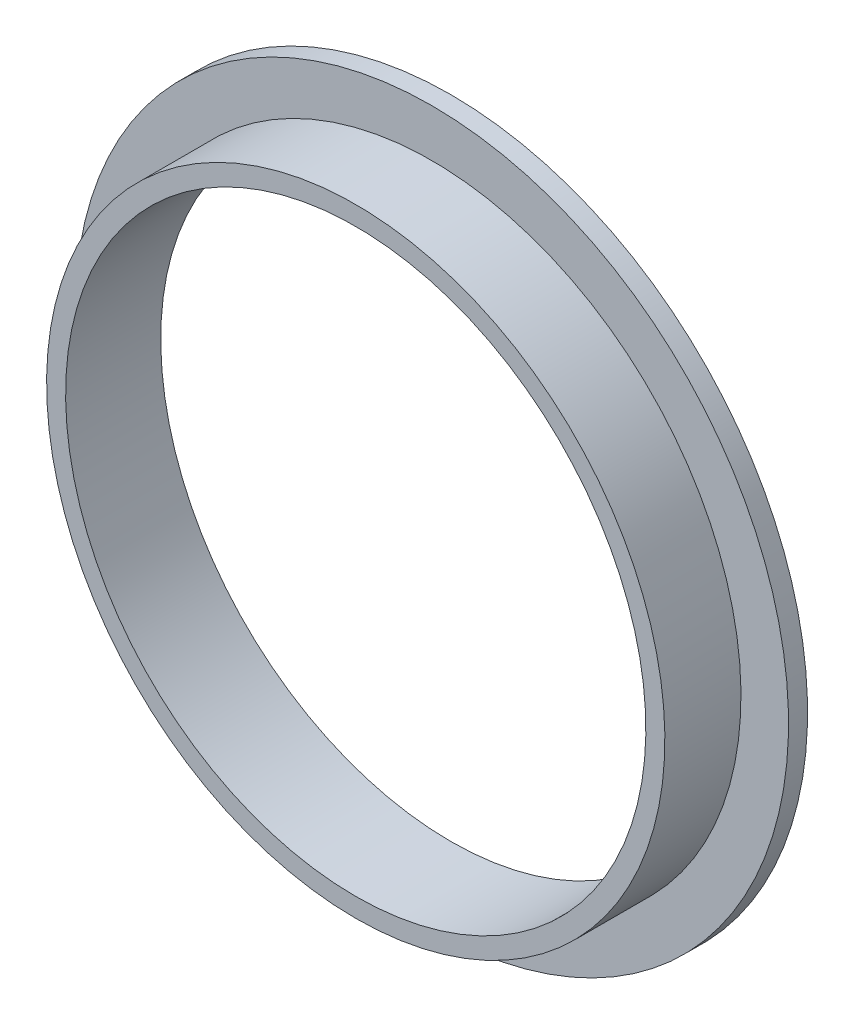
from build123d import *


with BuildPart() as part:
    # Sketch1 → Revolve1 (revolve)
    with BuildSketch(Plane(origin=(0, 0, 0), x_dir=(0, 0, -1), z_dir=(1, 0, 0))):
        Polygon((-7.9375, 48.41875), (7.9375, 48.41875), (7.9375, 59.53125), (4.7625, 59.53125), (4.7625, 51.59375), (-7.9375, 51.59375), align=None)
    revolve(axis=Axis((0, 0, 7.9375), (0, 0, -1)))


solid = part.part
